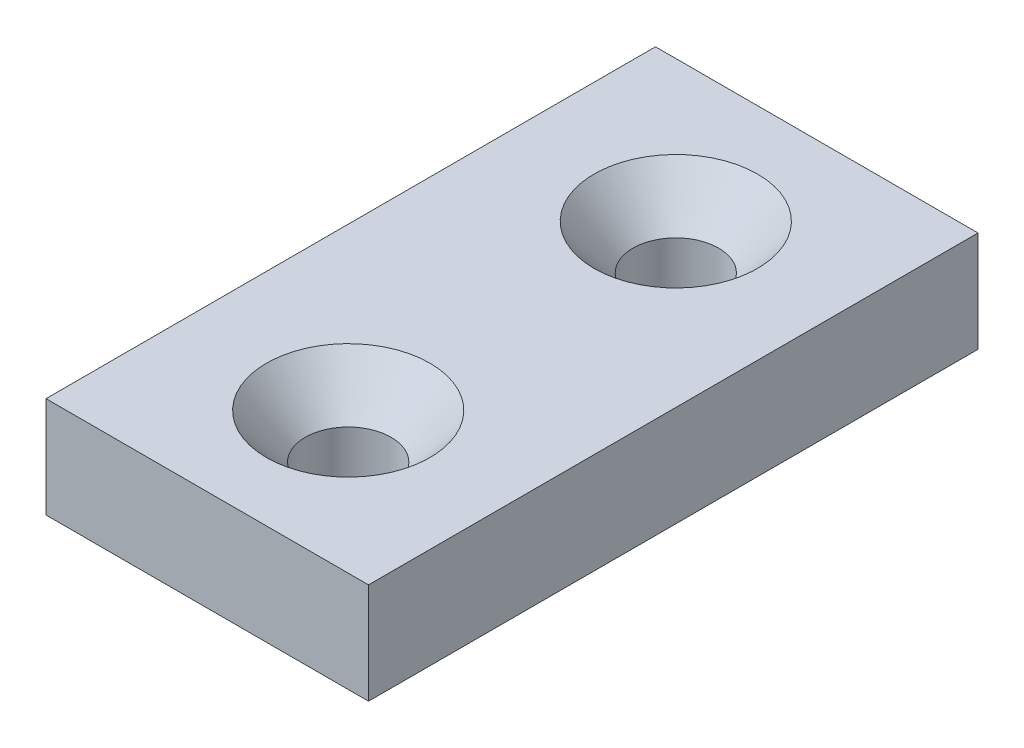
from build123d import *

# Parameters (mm, degrees)
SKETCH3_W                                        = 25.4
SKETCH3_H                                        = 7.9375
BOSS_EXTRUDE1_DEPTH                              = 24
CSK_FOR_1_4_FLAT_HEAD_MACHINE_SCREW1_D           = 6.7564
CSK_FOR_1_4_FLAT_HEAD_MACHINE_SCREW1_CSINK_D     = 12.8778
CSK_FOR_1_4_FLAT_HEAD_MACHINE_SCREW1_CSINK_ANGLE = 82


with BuildPart() as part:
    # Sketch3 → Boss-Extrude1 (new body, symmetric)
    with BuildSketch(Plane.XY):
        Rectangle(SKETCH3_W, SKETCH3_H)
    extrude(amount=BOSS_EXTRUDE1_DEPTH, both=True)

    # CSK for 1/4 Flat Head Machine Screw1 (through all)
    with Locations(Plane(origin=(0, 3.96875, 0), x_dir=(-1, 0, 0), z_dir=(0, 1, 0))):
        with Locations((0, 12.9), (0, -12.9)):
            CounterSinkHole(CSK_FOR_1_4_FLAT_HEAD_MACHINE_SCREW1_D / 2, CSK_FOR_1_4_FLAT_HEAD_MACHINE_SCREW1_CSINK_D / 2, counter_sink_angle=CSK_FOR_1_4_FLAT_HEAD_MACHINE_SCREW1_CSINK_ANGLE)


solid = part.part
